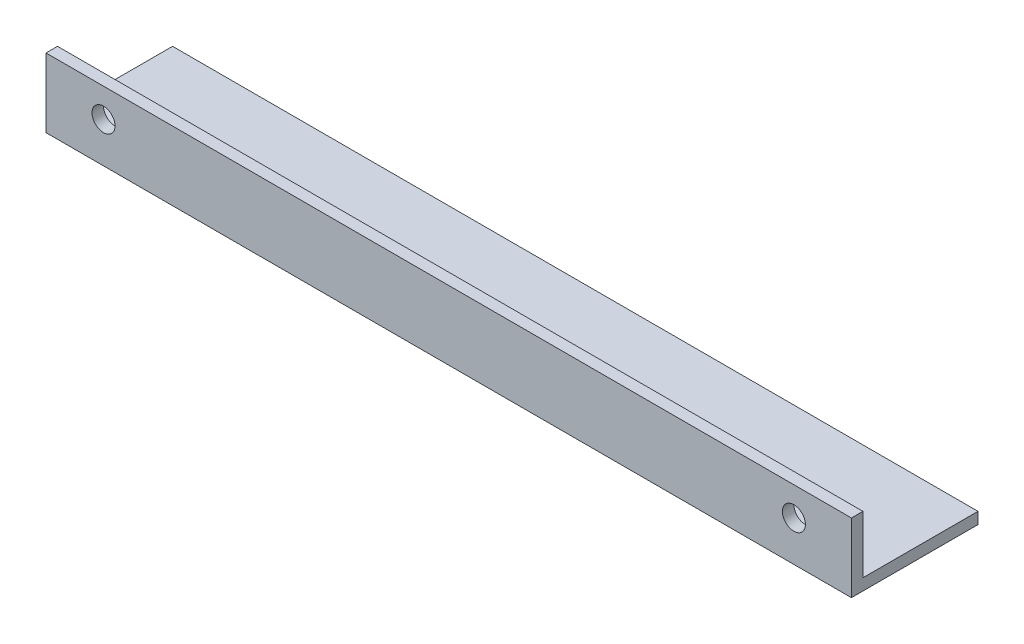
from build123d import *

# Parameters (mm, degrees)
SURFACE_EXTRUDE1_1_DEPTH = 140
THICKEN1_T2              = 2
SKETCH2_R                = 2
CUT_EXTRUDE2_DEPTH       = 142.774468788


with BuildPart() as body_1:
    # Surface-Extrude1: a surface, the sketch's curves swept straight by 140 mm
    with BuildLine(Plane(origin=(0, 0, 0), x_dir=(0, 0, -1), z_dir=(1, 0, 0)), mode=Mode.PRIVATE) as surface_extrude1_1_path:
        Line((0, 10), (0, 0))
        Line((0, 0), (20, 0))
    surface_extrude1_1 = Shell.extrude(surface_extrude1_1_path.wire(), (1 * SURFACE_EXTRUDE1_1_DEPTH, 0 * SURFACE_EXTRUDE1_1_DEPTH, 0 * SURFACE_EXTRUDE1_1_DEPTH))
    add(Solid.thicken(surface_extrude1_1, -THICKEN1_T2))

    # Sketch2 → Cut-Extrude2 (cut, through all)
    with BuildSketch(Plane(origin=(0, 0, 0), x_dir=(-1, 0, 0), z_dir=(0, 0, -1))):
        with Locations((-130, 5)):
            Circle(SKETCH2_R)
        with Locations(Location((-10, 5, 0), (0, 0, 180))):
            Circle(SKETCH2_R)
    extrude(amount=-CUT_EXTRUDE2_DEPTH, mode=Mode.SUBTRACT)


solid = body_1.part
